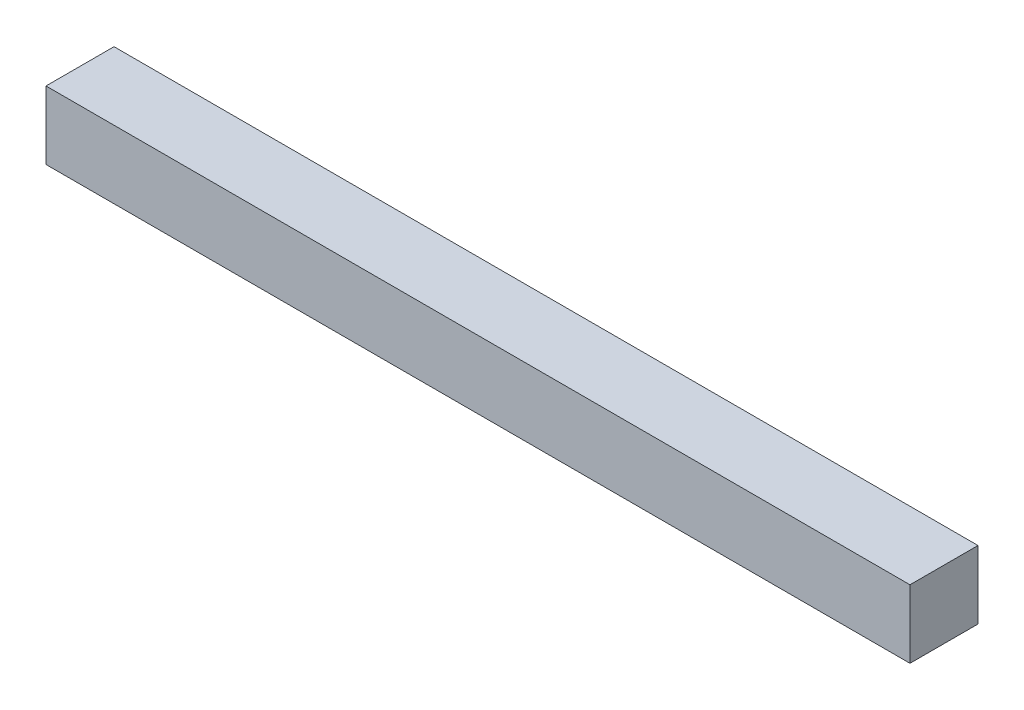
from build123d import *

# Parameters (mm, degrees)
ESQUISSE1_W        = 127
ESQUISSE1_H        = 10
BOSS_EXTRU_1_DEPTH = 10


with BuildPart() as part:
    # Esquisse1 → Boss.-Extru.1 (new body)
    with BuildSketch(Plane.XY):
        with Locations((48.799419052, 0.160818713)):
            Rectangle(ESQUISSE1_W, ESQUISSE1_H)
    extrude(amount=BOSS_EXTRU_1_DEPTH)


solid = part.part
